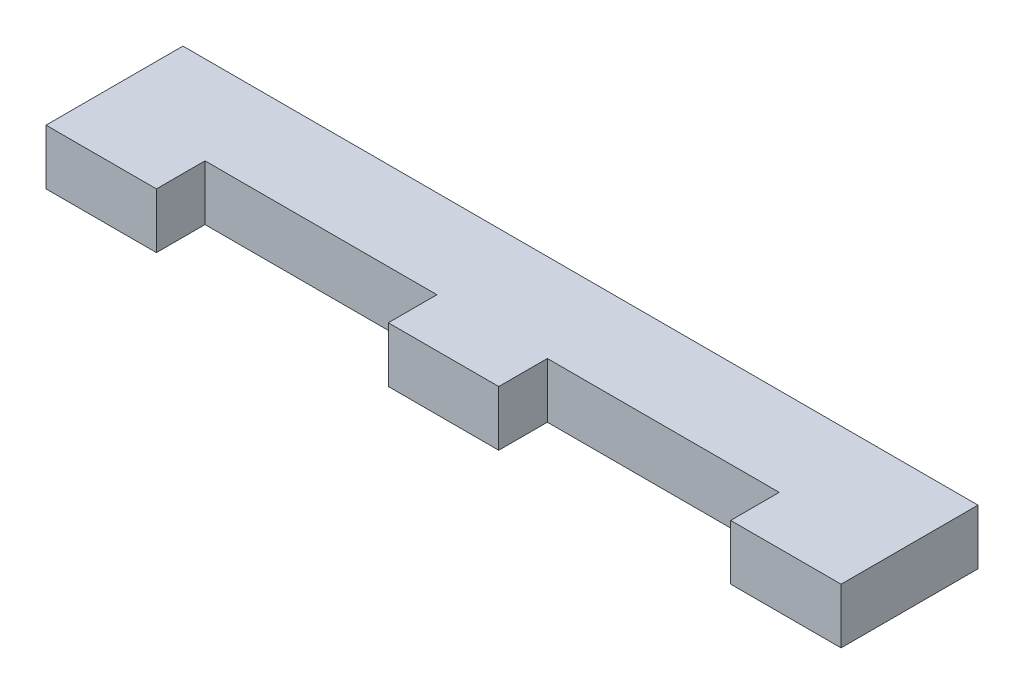
from build123d import *

# Parameters (mm, degrees)
BOSS_EXTRUDE1_DEPTH = 6.35


with BuildPart() as part:
    # Sketch1 → Boss-Extrude1 (new body)
    with BuildSketch(Plane(origin=(0, 0, 0), x_dir=(1, 0, 0), z_dir=(0, 1, 0))):
        Polygon((-6.35, -5.08), (-6.35, -10.668), (6.35, -10.668), (6.35, -5.08), (33.02, -5.08), (33.02, -10.668), (45.72, -10.668), (45.72, -5.08), (45.72, 5.08), (-45.72, 5.08), (-45.72, -5.08), (-45.72, -10.668), (-33.02, -10.668), (-33.02, -5.08), align=None)
    extrude(amount=BOSS_EXTRUDE1_DEPTH)


solid = part.part
